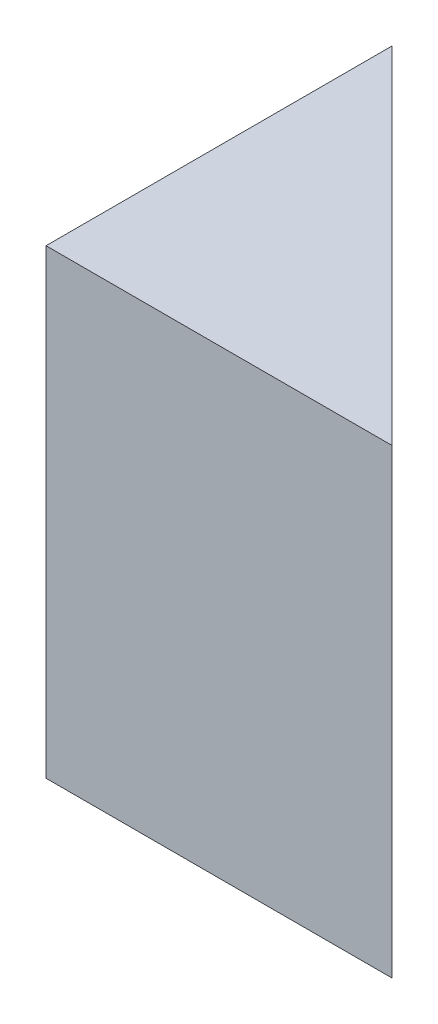
from build123d import *

# Parameters (mm, degrees)
BOSS_EXTRUDE1_DEPTH = 25.4


with BuildPart() as part:
    # Sketch1 → Boss-Extrude1 (new body)
    with BuildSketch(Plane(origin=(0, 0, 0), x_dir=(1, 0, 0), z_dir=(0, 1, 0))):
        Polygon((0, 19.05), (0, 0), (19.05, 0), align=None)
    extrude(amount=BOSS_EXTRUDE1_DEPTH)


solid = part.part
